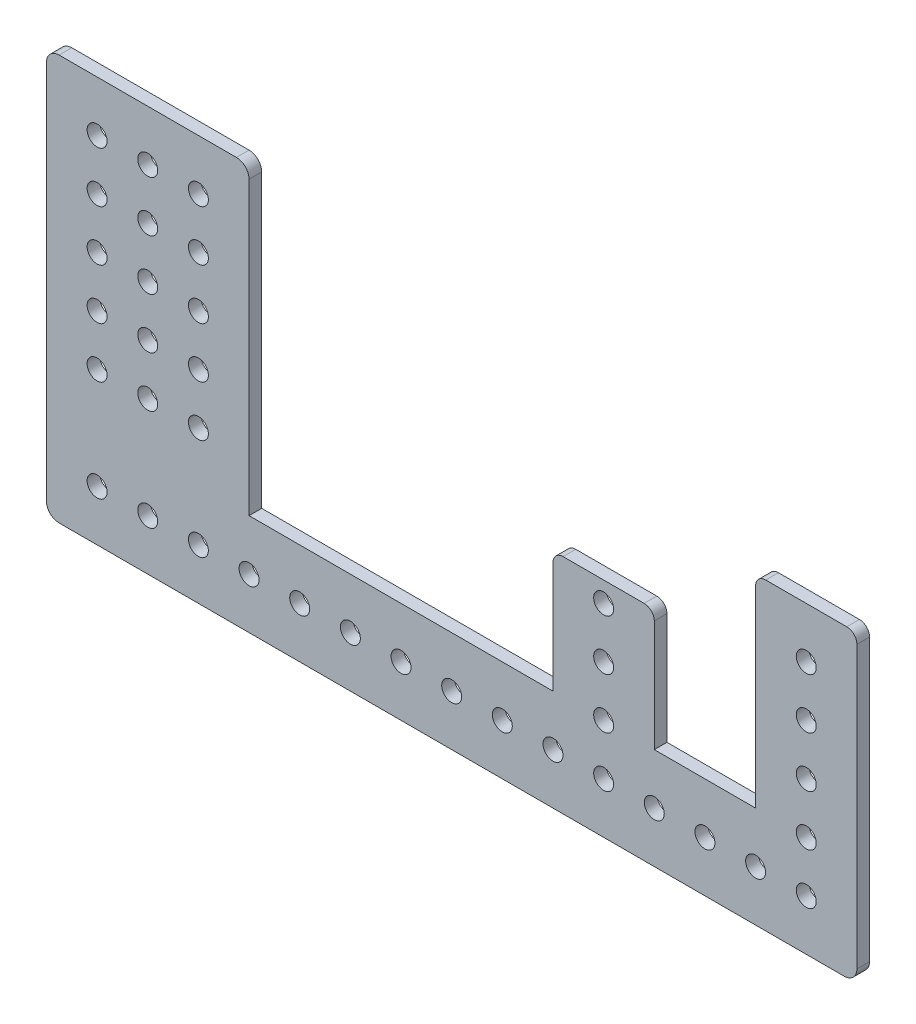
from build123d import *

# Parameters (mm, degrees)
BOSS_EXTRUDE1_DEPTH = 3.175
BOSS_EXTRUDE2_DEPTH = 3.175
SKETCH4_R           = 2.5
CUT_EXTRUDE1_DEPTH  = 4.175


with BuildPart() as part:
    # Sketch1 → Boss-Extrude1 (new body)
    with BuildSketch(Plane.XY):
        with BuildLine():
            Line((102.197610681, -20.076711723), (-50.202389319, -20.076711723))
            Line((-50.202389319, -20.076711723), (-50.202389319, 52.948288277))
            ThreePointArc((-50.202389319, 52.948288277), (-51.132325289, 55.193352307), (-53.377389319, 56.123288277))
            Line((-53.377389319, 56.123288277), (-97.827389319, 56.123288277))
            ThreePointArc((-97.827389319, 56.123288277), (-100.07245335, 55.193352307), (-101.002389319, 52.948288277))
            Line((-101.002389319, 52.948288277), (-101.002389319, -42.301711723))
            ThreePointArc((-101.002389319, -42.301711723), (-100.07245335, -44.546775753), (-97.827389319, -45.476711723))
            Line((-97.827389319, -45.476711723), (99.022610681, -45.476711723))
            ThreePointArc((99.022610681, -45.476711723), (101.267674711, -44.546775753), (102.197610681, -42.301711723))
            Line((102.197610681, -42.301711723), (102.197610681, -20.076711723))
        make_face()
    extrude(amount=BOSS_EXTRUDE1_DEPTH)

    # Sketch3 → Boss-Extrude2 (add)
    with BuildSketch(Plane.XY.offset(3.175)):
        with BuildLine():
            Line((48.857610681, 10.403288277), (28.537610681, 10.403288277))
            ThreePointArc((28.537610681, 10.403288277), (26.741559456, 9.659339501), (25.997610681, 7.863288277))
            Line((25.997610681, 7.863288277), (25.997610681, -20.076711723))
            Line((25.997610681, -20.076711723), (51.397610681, -20.076711723))
            Line((51.397610681, -20.076711723), (51.397610681, 7.863288277))
            ThreePointArc((51.397610681, 7.863288277), (50.653661905, 9.659339501), (48.857610681, 10.403288277))
        make_face()
        with BuildLine():
            Line((79.337610681, 30.723288277), (99.657610681, 30.723288277))
            ThreePointArc((99.657610681, 30.723288277), (101.453661905, 29.979339501), (102.197610681, 28.183288277))
            Line((102.197610681, 28.183288277), (102.197610681, -20.076711723))
            Line((102.197610681, -20.076711723), (76.797610681, -20.076711723))
            Line((76.797610681, -20.076711723), (76.797610681, 28.183288277))
            ThreePointArc((76.797610681, 28.183288277), (77.541559456, 29.979339501), (79.337610681, 30.723288277))
        make_face()
    extrude(amount=-BOSS_EXTRUDE2_DEPTH)

    # Sketch4 → Cut-Extrude1 (cut, through all)
    with BuildSketch(Plane.XY.offset(3.175)):
        with Locations((-88.302389319, -32.776711723)):
            Circle(SKETCH4_R)
        with Locations((-75.602389319, -32.776711723)):
            Circle(SKETCH4_R)
        with Locations((-62.902389319, -32.776711723)):
            Circle(SKETCH4_R)
        with Locations((-50.202389319, -32.776711723)):
            Circle(SKETCH4_R)
        with Locations((-37.502389319, -32.776711723)):
            Circle(SKETCH4_R)
        with Locations((-24.802389319, -32.776711723)):
            Circle(SKETCH4_R)
        with Locations((-12.102389319, -32.776711723)):
            Circle(SKETCH4_R)
        with Locations((0.597610681, -32.776711723)):
            Circle(SKETCH4_R)
        with Locations((13.297610681, -32.776711723)):
            Circle(SKETCH4_R)
        with Locations((25.997610681, -32.776711723)):
            Circle(SKETCH4_R)
        with Locations((38.697610681, -32.776711723)):
            Circle(SKETCH4_R)
        with Locations((51.397610681, -32.776711723)):
            Circle(SKETCH4_R)
        with Locations((64.097610681, -32.776711723)):
            Circle(SKETCH4_R)
        with Locations((76.797610681, -32.776711723)):
            Circle(SKETCH4_R)
        with Locations((89.497610681, -32.776711723)):
            Circle(SKETCH4_R)
        with Locations((38.697610681, -20.076711723)):
            Circle(SKETCH4_R)
        with Locations((89.497610681, -20.076711723)):
            Circle(SKETCH4_R)
        with Locations((-88.302389319, 43.423288277)):
            Circle(SKETCH4_R)
        with Locations((-62.902389319, 43.423288277)):
            Circle(SKETCH4_R)
        with Locations((-62.902389319, 30.723288277)):
            Circle(SKETCH4_R)
        with Locations((-62.902389319, 18.023288277)):
            Circle(SKETCH4_R)
        with Locations((-62.902389319, 5.323288277)):
            Circle(SKETCH4_R)
        with Locations((-62.902389319, -7.376711723)):
            Circle(SKETCH4_R)
        with Locations((-88.302389319, 30.723288277)):
            Circle(SKETCH4_R)
        with Locations((-88.302389319, 18.023288277)):
            Circle(SKETCH4_R)
        with Locations((-88.302389319, 5.323288277)):
            Circle(SKETCH4_R)
        with Locations((-88.302389319, -7.376711723)):
            Circle(SKETCH4_R)
        with Locations((38.697610681, -7.376711723)):
            Circle(SKETCH4_R)
        with Locations((89.497610681, -7.376711723)):
            Circle(SKETCH4_R)
        with Locations((38.697610681, 5.323288277)):
            Circle(SKETCH4_R)
        with Locations((89.497610681, 5.323288277)):
            Circle(SKETCH4_R)
        with Locations((89.497610681, 18.023288277)):
            Circle(SKETCH4_R)
        with Locations((-75.602389319, 43.423288277)):
            Circle(SKETCH4_R)
        with Locations((-75.602389319, 30.723288277)):
            Circle(SKETCH4_R)
        with Locations((-75.602389319, 18.023288277)):
            Circle(SKETCH4_R)
        with Locations((-75.602389319, 5.323288277)):
            Circle(SKETCH4_R)
        with Locations((-75.602389319, -7.376711723)):
            Circle(SKETCH4_R)
    extrude(amount=-CUT_EXTRUDE1_DEPTH, mode=Mode.SUBTRACT)


solid = part.part
